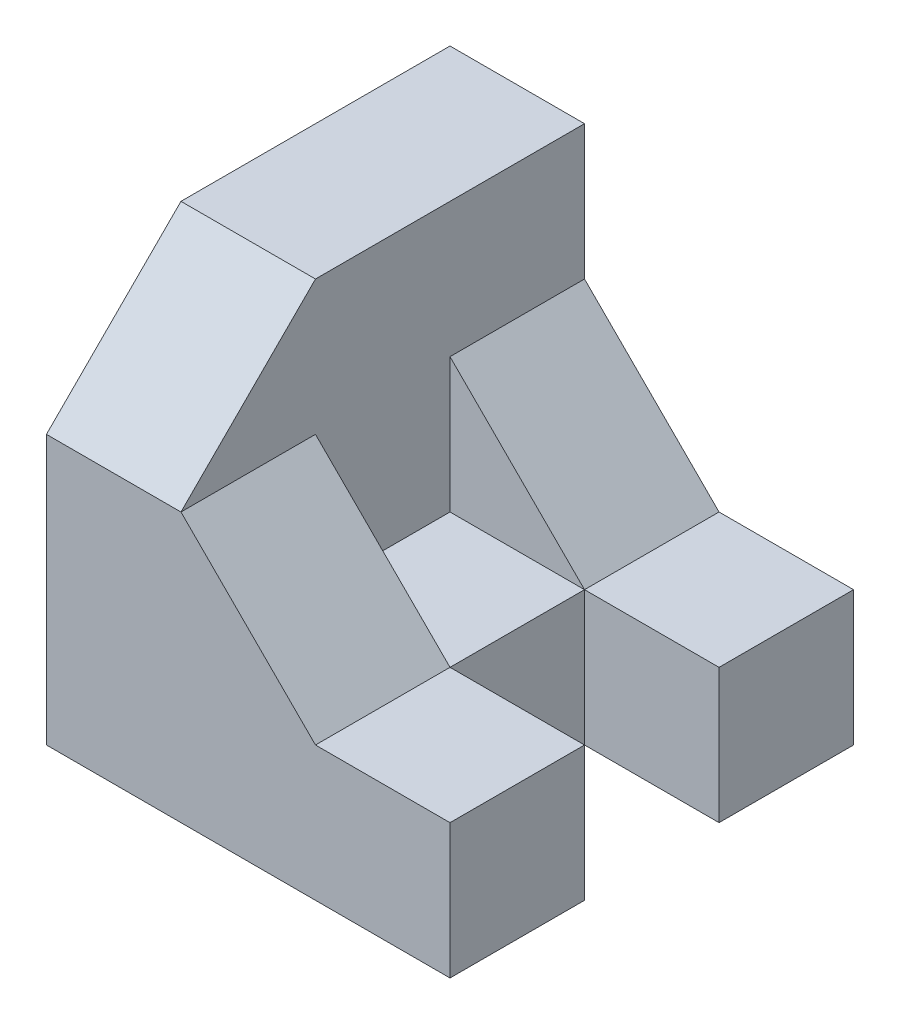
from build123d import *

# Parameters (mm, degrees)
CROQUIS1_W              = 60
CROQUIS1_H              = 60
SALIENTE_EXTRUIR1_DEPTH = 60
CROQUIS2_W              = 40
CROQUIS2_H              = 60
CORTAR_EXTRUIR1_DEPTH   = 20
CROQUIS3_W              = 20
CROQUIS3_H              = 60
CORTAR_EXTRUIR2_DEPTH   = 20
CORTAR_EXTRUIR3_DEPTH   = 20
CROQUIS7_W              = 20
CROQUIS7_H              = 20
CORTAR_EXTRUIR5_DEPTH   = 20
CORTAR_EXTRUIR6_DEPTH   = 60
CROQUIS8_W              = 20
CROQUIS8_H              = 20
CORTAR_EXTRUIR7_DEPTH   = 60


with BuildPart() as part:
    # Croquis1 → Saliente-Extruir1 (new body)
    with BuildSketch(Plane(origin=(0, 0, 0), x_dir=(1, 0, 0), z_dir=(0, 1, 0))):
        with Locations((30, -30)):
            Rectangle(CROQUIS1_W, CROQUIS1_H)
    extrude(amount=SALIENTE_EXTRUIR1_DEPTH)

    # Croquis2 → Cortar-Extruir1 (cut)
    with BuildSketch(Plane(origin=(0, 60, 0), x_dir=(1, 0, 0), z_dir=(0, 1, 0))):
        with Locations((40, -30)):
            Rectangle(CROQUIS2_W, CROQUIS2_H)
    extrude(amount=-CORTAR_EXTRUIR1_DEPTH, mode=Mode.SUBTRACT)

    # Croquis3 → Cortar-Extruir2 (cut)
    with BuildSketch(Plane(origin=(0, 40, 0), x_dir=(1, 0, 0), z_dir=(0, 1, 0))):
        with Locations((50, -30)):
            Rectangle(CROQUIS3_W, CROQUIS3_H)
    extrude(amount=-CORTAR_EXTRUIR2_DEPTH, mode=Mode.SUBTRACT)

    # Croquis4 → Cortar-Extruir3 (cut)
    with BuildSketch(Plane(origin=(20, 0, 0), x_dir=(0, 0, -1), z_dir=(1, 0, 0))):
        Polygon((-60, 40), (-60, 60), (-40, 60), align=None)
    extrude(amount=-CORTAR_EXTRUIR3_DEPTH, mode=Mode.SUBTRACT)

    # Croquis7 → Cortar-Extruir5 (cut)
    with BuildSketch(Plane(origin=(0, 40, 0), x_dir=(1, 0, 0), z_dir=(0, 1, 0))):
        with Locations((30, -30)):
            Rectangle(CROQUIS7_W, CROQUIS7_H)
    extrude(amount=-CORTAR_EXTRUIR5_DEPTH, mode=Mode.SUBTRACT)

    # Croquis5 → Cortar-Extruir6 (cut)
    with BuildSketch(Plane.XY.offset(60)):
        Polygon((20, 40), (40, 20), (40, 40), align=None)
    extrude(amount=-CORTAR_EXTRUIR6_DEPTH, mode=Mode.SUBTRACT)

    # Croquis8 → Cortar-Extruir7 (cut)
    with BuildSketch(Plane(origin=(0, 20, 0), x_dir=(1, 0, 0), z_dir=(0, 1, 0))):
        with Locations((50, -30)):
            Rectangle(CROQUIS8_W, CROQUIS8_H)
    extrude(amount=-CORTAR_EXTRUIR7_DEPTH, mode=Mode.SUBTRACT)


solid = part.part
